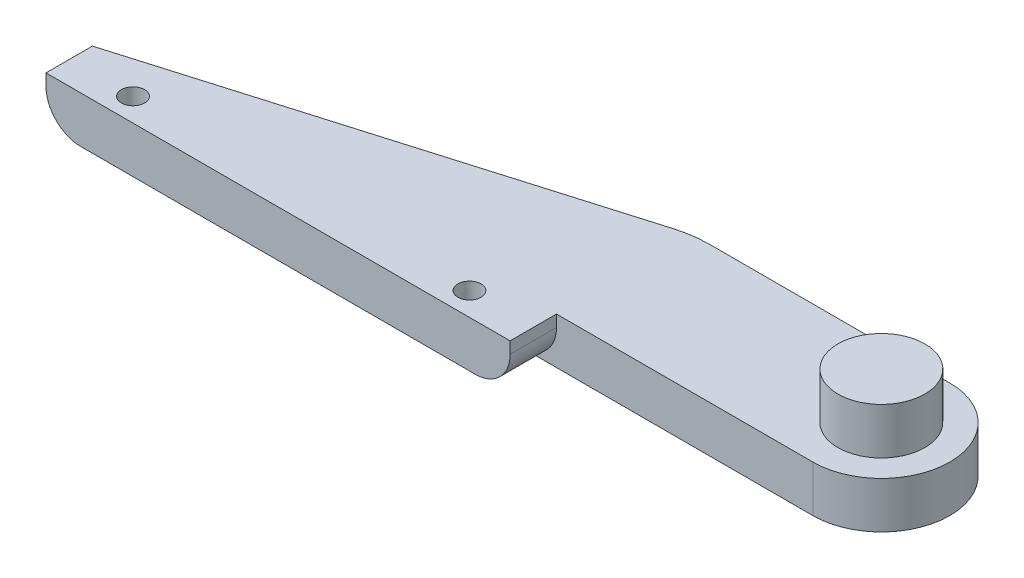
from build123d import *

# Parameters (mm, degrees)
BOSS_EXTRUDE2_DEPTH = 4
SKETCH4_R           = 3.746181505
BOSS_EXTRUDE3_DEPTH = 4
SKETCH5_R           = 1
CUT_EXTRUDE1_DEPTH  = 9
FILLET1_R           = 10
FILLET3_R           = 3


with BuildPart() as part:
    # Sketch1 → Boss-Extrude2 (new body)
    with BuildSketch(Plane(origin=(0, 0, 0), x_dir=(1, 0, 0), z_dir=(0, 1, 0))):
        with BuildLine():
            Line((-20, 2), (20, 13.8))
            Line((20, 13.8), (42.1, 13.8))
            ThreePointArc((42.1, 13.8), (48, 7.9), (42.1, 2))
            Line((42.1, 2), (20, 2))
            Line((20, 2), (20, -2))
            Line((20, -2), (-20, -2))
            Line((-20, -2), (-20, 2))
        make_face()
    extrude(amount=BOSS_EXTRUDE2_DEPTH)

    # Sketch4 → Boss-Extrude3 (add)
    with BuildSketch(Plane(origin=(0, 4, 0), x_dir=(-1, 0, 0), z_dir=(0, -1, 0))):
        with Locations((-42.1, 7.9)):
            Circle(SKETCH4_R)
    extrude(amount=-BOSS_EXTRUDE3_DEPTH)

    # Sketch5 → Cut-Extrude1 (cut, through all)
    with BuildSketch(Plane(origin=(0, 0, 0), x_dir=(-1, 0, 0), z_dir=(0, -1, 0))):
        with Locations((14.5, 0)):
            Circle(SKETCH5_R)
        with Locations((-14.5, 0)):
            Circle(SKETCH5_R)
    extrude(amount=-CUT_EXTRUDE1_DEPTH, mode=Mode.SUBTRACT)

    # Fillet1
    fillet1_edges = [part.edges().sort_by_distance(p)[0] for p in [
        (20, 2, -13.8),
    ]]
    fillet(fillet1_edges, radius=FILLET1_R)

    # Fillet3
    fillet3_edges = [part.edges().sort_by_distance(p)[0] for p in [
        (20, 0, 0),
        (-20, 0, 0),
    ]]
    fillet(fillet3_edges, radius=FILLET3_R)


solid = part.part
